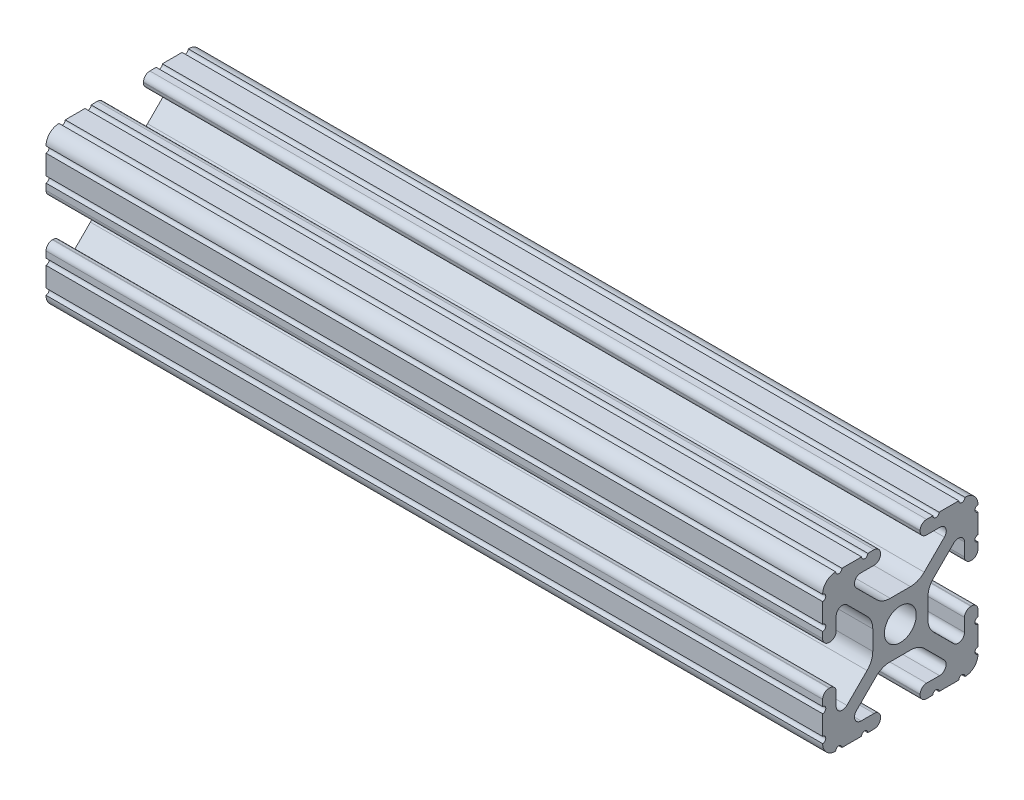
from build123d import *

# Parameters (mm, degrees)
SKETCH1_R           = 2.6035
BOSS_EXTRUDE1_DEPTH = 63.5


with BuildPart() as part:
    # Sketch1 → Boss-Extrude1 (new body, symmetric)
    with BuildSketch(Plane(origin=(0, 0, 0), x_dir=(0, 0, -1), z_dir=(1, 0, 0))):
        with BuildLine():
            Line((6.333126718, -12.7), (9.550443118, -12.7))
            ThreePointArc((9.550443118, -12.7), (10.058366869, -12.192000006), (10.566443095, -12.699847501))
            ThreePointArc((10.566443095, -12.699847501), (12.082537762, -12.08250727), (12.699846982, -10.566399977))
            ThreePointArc((12.699846982, -10.566399977), (12.192000006, -10.058323491), (12.7, -9.5504))
            Line((12.7, -9.5504), (12.7, -6.3330836))
            ThreePointArc((12.7, -6.3330836), (12.192, -5.8250836), (12.7, -5.3170836))
            Line((12.7, -5.3170836), (12.7, -4.287469289))
            ThreePointArc((12.7, -4.287469289), (12.39275138, -3.545705502), (11.650987593, -3.238456882))
            Line((11.650987593, -3.238456882), (11.539212407, -3.238456882))
            ThreePointArc((11.539212407, -3.238456882), (10.79744862, -3.545705502), (10.4902, -4.287469289))
            Line((10.4902, -4.287469289), (10.4902, -6.402089023))
            ThreePointArc((10.4902, -6.402089023), (9.856505071, -7.351067942), (8.737131347, -7.129408934))
            Line((8.737131347, -7.129408934), (5.441005833, -3.840816462))
            ThreePointArc((5.441005833, -3.840816462), (4.750877967, -2.809883091), (4.5085, -1.593185507))
            Line((4.5085, -1.593185507), (4.5085, 1.593185507))
            ThreePointArc((4.5085, 1.593185507), (4.750877967, 2.809883091), (5.441005833, 3.840816462))
            Line((5.441005833, 3.840816462), (8.737131347, 7.129408934))
            ThreePointArc((8.737131347, 7.129408934), (9.856505071, 7.351067942), (10.4902, 6.402089023))
            Line((10.4902, 6.402089023), (10.4902, 4.287469289))
            ThreePointArc((10.4902, 4.287469289), (10.79744862, 3.545705502), (11.539212407, 3.238456882))
            Line((11.539212407, 3.238456882), (11.650987593, 3.238456882))
            ThreePointArc((11.650987593, 3.238456882), (12.39275138, 3.545705502), (12.7, 4.287469289))
            Line((12.7, 4.287469289), (12.7, 5.3170836))
            ThreePointArc((12.7, 5.3170836), (12.192, 5.8250836), (12.7, 6.3330836))
            Line((12.7, 6.3330836), (12.7, 9.5504))
            ThreePointArc((12.7, 9.5504), (12.192000006, 10.058323491), (12.699846982, 10.566399977))
            ThreePointArc((12.699846982, 10.566399977), (12.082537762, 12.08250727), (10.566443095, 12.699847501))
            ThreePointArc((10.566443095, 12.699847501), (10.058366869, 12.192000006), (9.550443118, 12.7))
            Line((9.550443118, 12.7), (6.333126718, 12.7))
            ThreePointArc((6.333126718, 12.7), (5.825126718, 12.192), (5.317126718, 12.7))
            Line((5.317126718, 12.7), (4.287512407, 12.7))
            ThreePointArc((4.287512407, 12.7), (3.54574862, 12.39275138), (3.2385, 11.650987593))
            Line((3.2385, 11.650987593), (3.2385, 11.539212407))
            ThreePointArc((3.2385, 11.539212407), (3.54574862, 10.79744862), (4.287512407, 10.4902))
            Line((4.287512407, 10.4902), (6.476788598, 10.4902))
            ThreePointArc((6.476788598, 10.4902), (7.432222385, 9.85140422), (7.207036008, 8.724370562))
            Line((7.207036008, 8.724370562), (3.898272566, 5.423169045))
            ThreePointArc((3.898272566, 5.423169045), (2.869120213, 4.736787962), (1.655778399, 4.4958))
            Line((1.655778399, 4.4958), (-1.655778399, 4.4958))
            ThreePointArc((-1.655778399, 4.4958), (-2.869120213, 4.736787962), (-3.898272566, 5.423169045))
            Line((-3.898272566, 5.423169045), (-7.207036008, 8.724370562))
            ThreePointArc((-7.207036008, 8.724370562), (-7.432222385, 9.85140422), (-6.476788598, 10.4902))
            Line((-6.476788598, 10.4902), (-4.287512407, 10.4902))
            ThreePointArc((-4.287512407, 10.4902), (-3.54574862, 10.79744862), (-3.2385, 11.539212407))
            Line((-3.2385, 11.539212407), (-3.2385, 11.650987593))
            ThreePointArc((-3.2385, 11.650987593), (-3.54574862, 12.39275138), (-4.287512407, 12.7))
            Line((-4.287512407, 12.7), (-5.317126718, 12.7))
            ThreePointArc((-5.317126718, 12.7), (-5.825126718, 12.192), (-6.333126718, 12.7))
            Line((-6.333126718, 12.7), (-9.550443118, 12.7))
            ThreePointArc((-9.550443118, 12.7), (-10.058366869, 12.192000006), (-10.566443095, 12.699847501))
            ThreePointArc((-10.566443095, 12.699847501), (-12.082537762, 12.08250727), (-12.699846982, 10.566399977))
            ThreePointArc((-12.699846982, 10.566399977), (-12.192000006, 10.058323491), (-12.7, 9.5504))
            Line((-12.7, 9.5504), (-12.7, 6.3330836))
            ThreePointArc((-12.7, 6.3330836), (-12.192, 5.8250836), (-12.7, 5.3170836))
            Line((-12.7, 5.3170836), (-12.7, 4.287469289))
            ThreePointArc((-12.7, 4.287469289), (-12.39275138, 3.545705502), (-11.650987593, 3.238456882))
            Line((-11.650987593, 3.238456882), (-11.539212407, 3.238456882))
            ThreePointArc((-11.539212407, 3.238456882), (-10.79744862, 3.545705502), (-10.4902, 4.287469289))
            Line((-10.4902, 4.287469289), (-10.4902, 6.402089023))
            ThreePointArc((-10.4902, 6.402089023), (-9.856505071, 7.351067942), (-8.737131347, 7.129408934))
            Line((-8.737131347, 7.129408934), (-5.441005833, 3.840816462))
            ThreePointArc((-5.441005833, 3.840816462), (-4.750877967, 2.809883091), (-4.5085, 1.593185507))
            Line((-4.5085, 1.593185507), (-4.5085, -1.593185507))
            ThreePointArc((-4.5085, -1.593185507), (-4.750877967, -2.809883091), (-5.441005833, -3.840816462))
            Line((-5.441005833, -3.840816462), (-8.737131347, -7.129408934))
            ThreePointArc((-8.737131347, -7.129408934), (-9.856505071, -7.351067942), (-10.4902, -6.402089023))
            Line((-10.4902, -6.402089023), (-10.4902, -4.287469289))
            ThreePointArc((-10.4902, -4.287469289), (-10.79744862, -3.545705502), (-11.539212407, -3.238456882))
            Line((-11.539212407, -3.238456882), (-11.650987593, -3.238456882))
            ThreePointArc((-11.650987593, -3.238456882), (-12.39275138, -3.545705502), (-12.7, -4.287469289))
            Line((-12.7, -4.287469289), (-12.7, -5.3170836))
            ThreePointArc((-12.7, -5.3170836), (-12.192, -5.8250836), (-12.7, -6.3330836))
            Line((-12.7, -6.3330836), (-12.7, -9.5504))
            ThreePointArc((-12.7, -9.5504), (-12.192000006, -10.058323491), (-12.699846982, -10.566399977))
            ThreePointArc((-12.699846982, -10.566399977), (-12.082537762, -12.08250727), (-10.566443095, -12.699847501))
            ThreePointArc((-10.566443095, -12.699847501), (-10.058366869, -12.192000006), (-9.550443118, -12.7))
            Line((-9.550443118, -12.7), (-6.333126718, -12.7))
            ThreePointArc((-6.333126718, -12.7), (-5.825126718, -12.192), (-5.317126718, -12.7))
            Line((-5.317126718, -12.7), (-4.287512407, -12.7))
            ThreePointArc((-4.287512407, -12.7), (-3.54574862, -12.39275138), (-3.2385, -11.650987593))
            Line((-3.2385, -11.650987593), (-3.2385, -11.539212407))
            ThreePointArc((-3.2385, -11.539212407), (-3.54574862, -10.79744862), (-4.287512407, -10.4902))
            Line((-4.287512407, -10.4902), (-6.416408329, -10.4902))
            ThreePointArc((-6.416408329, -10.4902), (-7.41473083, -9.822813117), (-7.179650497, -8.645192506))
            Line((-7.179650497, -8.645192506), (-3.952270251, -5.423690499))
            ThreePointArc((-3.952270251, -5.423690499), (-2.922936451, -4.736929036), (-1.709253557, -4.4958))
            Line((-1.709253557, -4.4958), (1.709253557, -4.4958))
            ThreePointArc((1.709253557, -4.4958), (2.922936451, -4.736929036), (3.952270251, -5.423690499))
            Line((3.952270251, -5.423690499), (7.179650497, -8.645192506))
            ThreePointArc((7.179650497, -8.645192506), (7.41473083, -9.822813117), (6.416408329, -10.4902))
            Line((6.416408329, -10.4902), (4.287512407, -10.4902))
            ThreePointArc((4.287512407, -10.4902), (3.54574862, -10.79744862), (3.2385, -11.539212407))
            Line((3.2385, -11.539212407), (3.2385, -11.650987593))
            ThreePointArc((3.2385, -11.650987593), (3.54574862, -12.39275138), (4.287512407, -12.7))
            Line((4.287512407, -12.7), (5.317126718, -12.7))
            ThreePointArc((5.317126718, -12.7), (5.825126718, -12.192), (6.333126718, -12.7))
        make_face()
        Circle(SKETCH1_R, mode=Mode.SUBTRACT)
    extrude(amount=BOSS_EXTRUDE1_DEPTH, both=True)


solid = part.part
